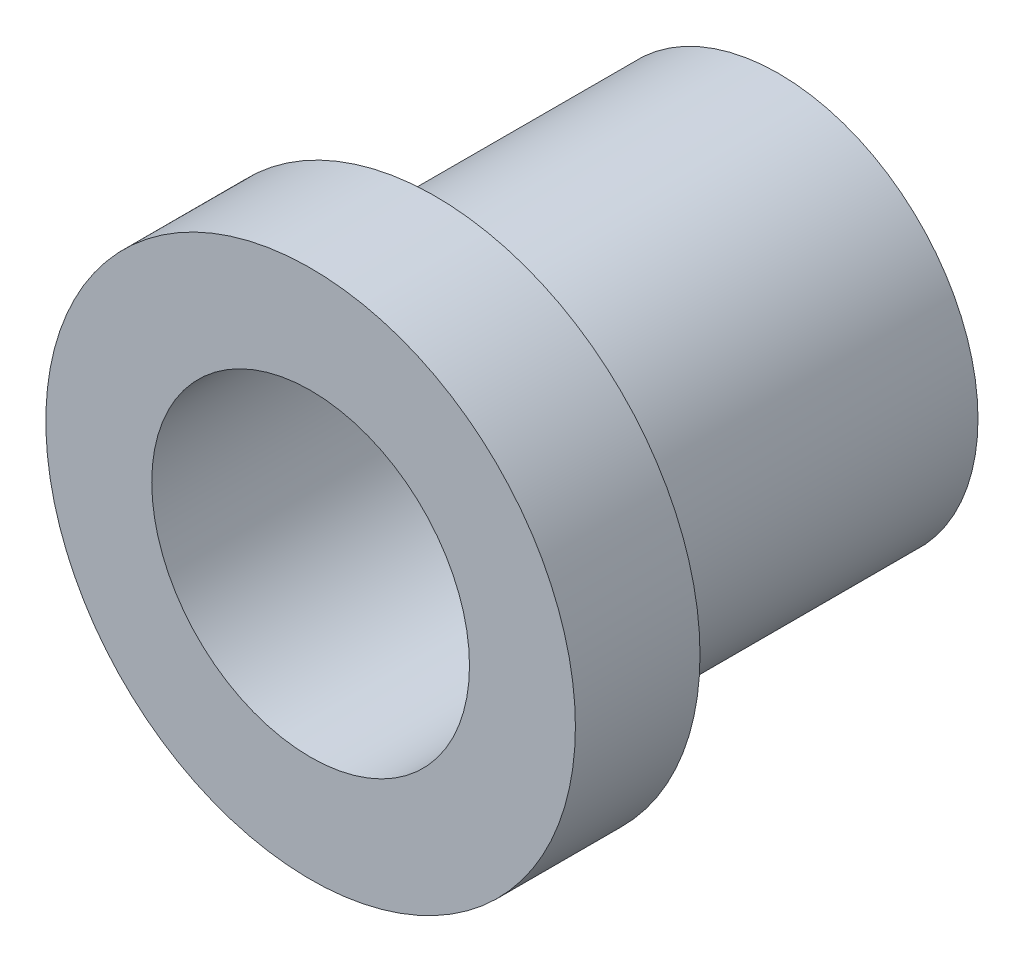
from build123d import *

# Parameters (mm, degrees)
SKETCH1_R           = 5.3975
SKETCH1_R_2         = 3.2385
BOSS_EXTRUDE1_DEPTH = 2.54
SKETCH2_R           = 4.064
SKETCH2_R_2         = 3.2385
BOSS_EXTRUDE2_DEPTH = 7


with BuildPart() as part:
    # Sketch1 → Boss-Extrude1 (new body)
    with BuildSketch(Plane.XY):
        Circle(SKETCH1_R)
        Circle(SKETCH1_R_2, mode=Mode.SUBTRACT)
    extrude(amount=BOSS_EXTRUDE1_DEPTH)

    # Sketch2 → Boss-Extrude2 (add)
    with BuildSketch(Plane(origin=(0, 0, 0), x_dir=(-1, 0, 0), z_dir=(0, 0, -1))):
        Circle(SKETCH2_R)
        Circle(SKETCH2_R_2, mode=Mode.SUBTRACT)
    extrude(amount=BOSS_EXTRUDE2_DEPTH)


solid = part.part
